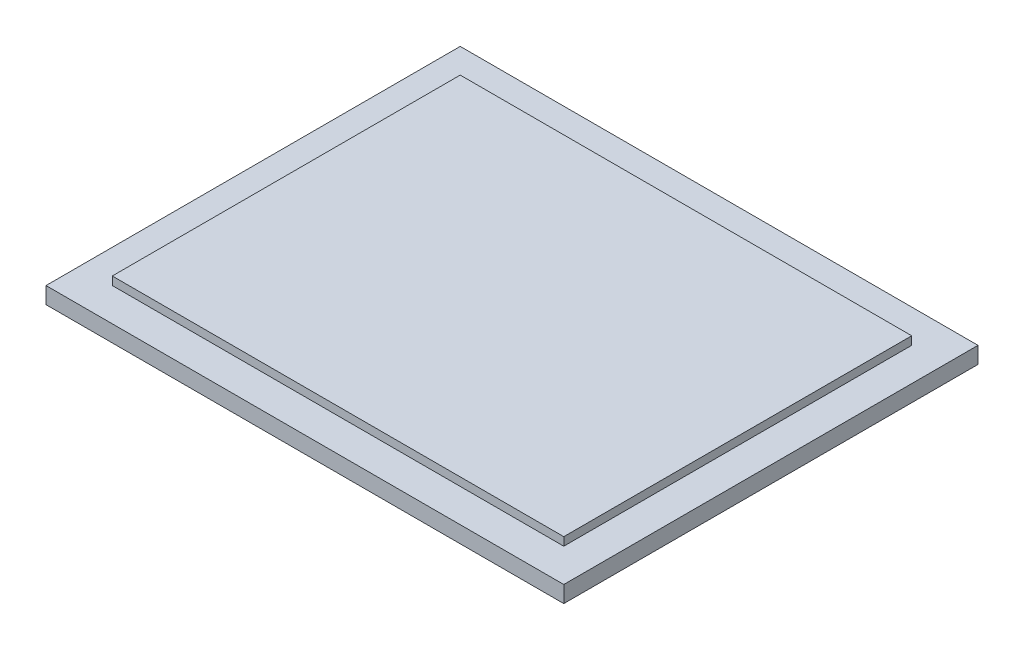
from build123d import *

# Parameters (mm, degrees)
SKETCH1_W           = 125
SKETCH1_H           = 100
BOSS_EXTRUDE1_DEPTH = 4
SKETCH2_W           = 109
SKETCH2_H           = 84
BOSS_EXTRUDE2_DEPTH = 2


with BuildPart() as part:
    # Sketch1 → Boss-Extrude1 (new body)
    with BuildSketch(Plane(origin=(0, 0, 0), x_dir=(1, 0, 0), z_dir=(0, 1, 0))):
        with Locations((8.504254172, -30.793782172)):
            Rectangle(SKETCH1_W, SKETCH1_H)
    extrude(amount=BOSS_EXTRUDE1_DEPTH)

    # Sketch2 → Boss-Extrude2 (add)
    with BuildSketch(Plane(origin=(0, 4, 0), x_dir=(1, 0, 0), z_dir=(0, 1, 0))):
        with Locations((8.504254172, -30.793782172)):
            Rectangle(SKETCH2_W, SKETCH2_H)
    extrude(amount=BOSS_EXTRUDE2_DEPTH)


solid = part.part
